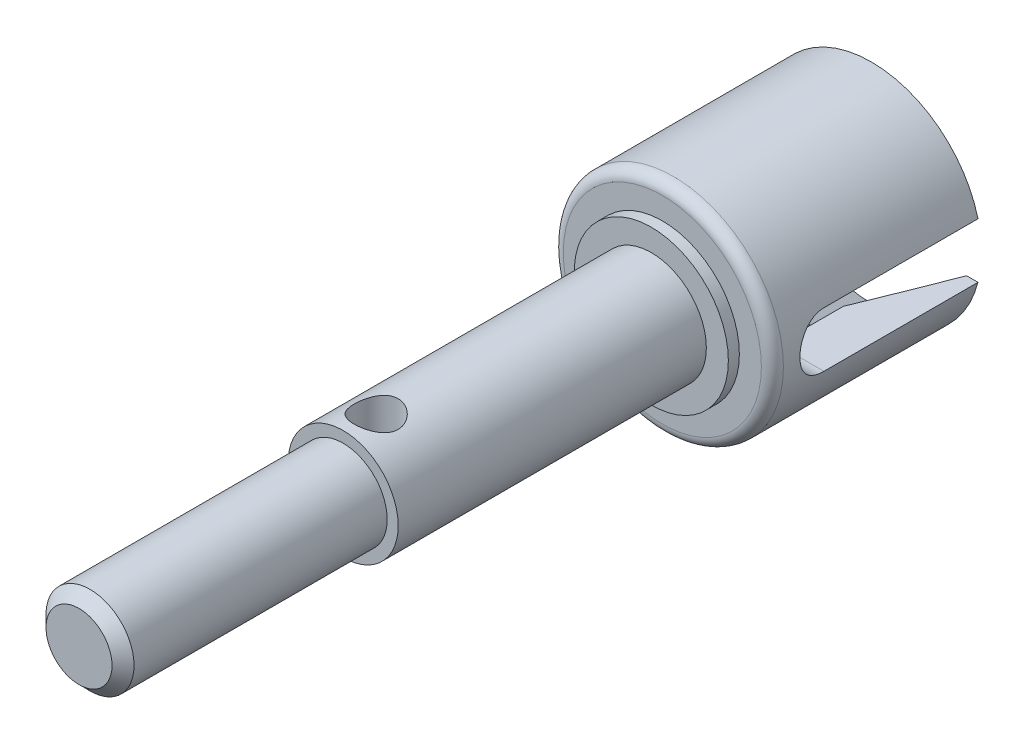
from build123d import *

# Parameters (mm, degrees)
ESQUISSE1_R             = 5
BASE_EXTRUSION_DEPTH    = 9.5
ESQUISSE2_R             = 3.5
BOSS_EXTRU_1_DEPTH      = 0.5
ESQUISSE3_R             = 2.5
BOSS_EXTRU_2_DEPTH      = 14
ESQUISSE4_R             = 2
BOSS_EXTRU_3_DEPTH      = 12
CHANFREIN1_SIZE         = 0.5
CONG_1_R                = 0.5
ENL_V_MAT_EXTRU_1_DEPTH = 16
ESQUISSE9_R             = 1
ENL_V_MAT_EXTRU_2_DEPTH = 10


with BuildPart() as part:
    # Esquisse1 → Base-Extrusion (new body)
    with BuildSketch(Plane.XY):
        Circle(ESQUISSE1_R)
    extrude(amount=BASE_EXTRUSION_DEPTH)

    # Esquisse2 → Boss.-Extru.1 (add)
    with BuildSketch(Plane.XY.offset(9.5)):
        Circle(ESQUISSE2_R)
    extrude(amount=BOSS_EXTRU_1_DEPTH)

    # Esquisse3 → Boss.-Extru.2 (add)
    with BuildSketch(Plane.XY.offset(10)):
        Circle(ESQUISSE3_R)
    extrude(amount=BOSS_EXTRU_2_DEPTH)

    # Esquisse4 → Boss.-Extru.3 (add)
    with BuildSketch(Plane.XY.offset(24)):
        Circle(ESQUISSE4_R)
    extrude(amount=BOSS_EXTRU_3_DEPTH)

    # Chanfrein1
    chanfrein1_edges = [part.edges().sort_by_distance(p)[0] for p in [
        (-2, 0, 36),
    ]]
    chamfer(chanfrein1_edges, length=CHANFREIN1_SIZE)

    # Congé1
    cong_1_edges = [part.edges().sort_by_distance(p)[0] for p in [
        (-5, 0, 9.5),
    ]]
    fillet(cong_1_edges, radius=CONG_1_R)

    # Esquisse7 → Enlèv. mat.-Extru.1 (cut, symmetric)
    with BuildSketch(Plane(origin=(0, 0, 0), x_dir=(0, 0, -1), z_dir=(1, 0, 0))):
        with BuildLine():
            Line((1, 1.25), (-7, 1.25))
            ThreePointArc((-7, 1.25), (-8.25, 0), (-7, -1.25))
            Line((-7, -1.25), (1, -1.25))
            Line((1, -1.25), (1, 1.25))
        make_face()
    extrude(amount=ENL_V_MAT_EXTRU_1_DEPTH, both=True, mode=Mode.SUBTRACT)

    # Esquisse8 → Enlèvement de matière-Révolution1 (revolve, cut)
    with BuildSketch(Plane(origin=(0, 0, 0), x_dir=(0, 0, -1), z_dir=(1, 0, 0))):
        Polygon((0, 4.5), (-4, 3), (-8, 3), (-9.5, 0), (0, 0), align=None)
    revolve(axis=Axis((0, 0, 0), (0, 0, 1)), mode=Mode.SUBTRACT)

    # Esquisse9 → Enlèv. mat.-Extru.2 (cut, symmetric)
    with BuildSketch(Plane(origin=(0, 0, 0), x_dir=(1, 0, 0), z_dir=(0, 1, 0))):
        with Locations((0, -22.5)):
            Circle(ESQUISSE9_R)
    extrude(amount=ENL_V_MAT_EXTRU_2_DEPTH, both=True, mode=Mode.SUBTRACT)


solid = part.part
